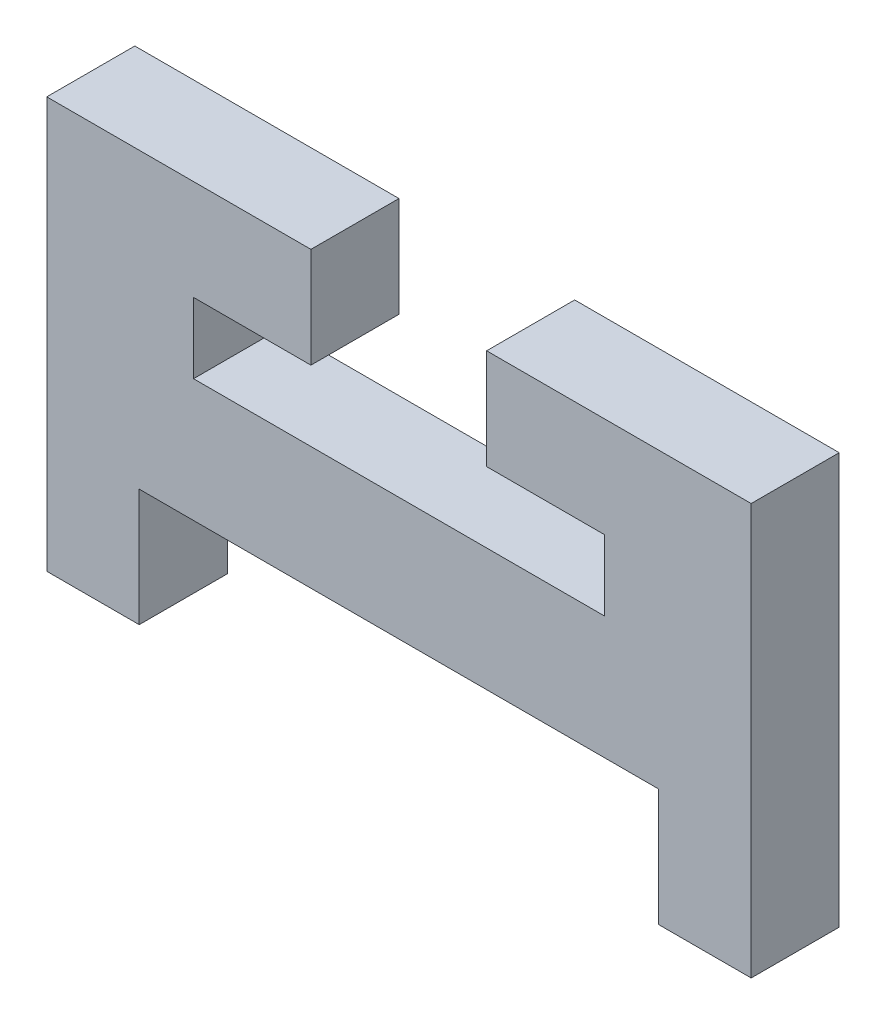
from build123d import *

# Parameters (mm, degrees)
SALIENTE_EXTRUIR1_DEPTH = 3


with BuildPart() as part:
    # Model → Saliente-Extruir1 (new body)
    with BuildSketch(Plane.XY):
        Polygon((29.5, 19.682683294), (22, 19.682683294), (22, 22.082683294), (26, 22.082683294), (26, 25.5), (17, 25.5), (17, 11.5), (20.15, 11.5), (20.15, 15.5), (37.85, 15.5), (37.85, 11.5), (41, 11.5), (41, 25.5), (31.986385402, 25.5), (31.986385402, 22.082683294), (36, 22.082683294), (36, 19.682683294), align=None)
    extrude(amount=SALIENTE_EXTRUIR1_DEPTH)


solid = part.part
